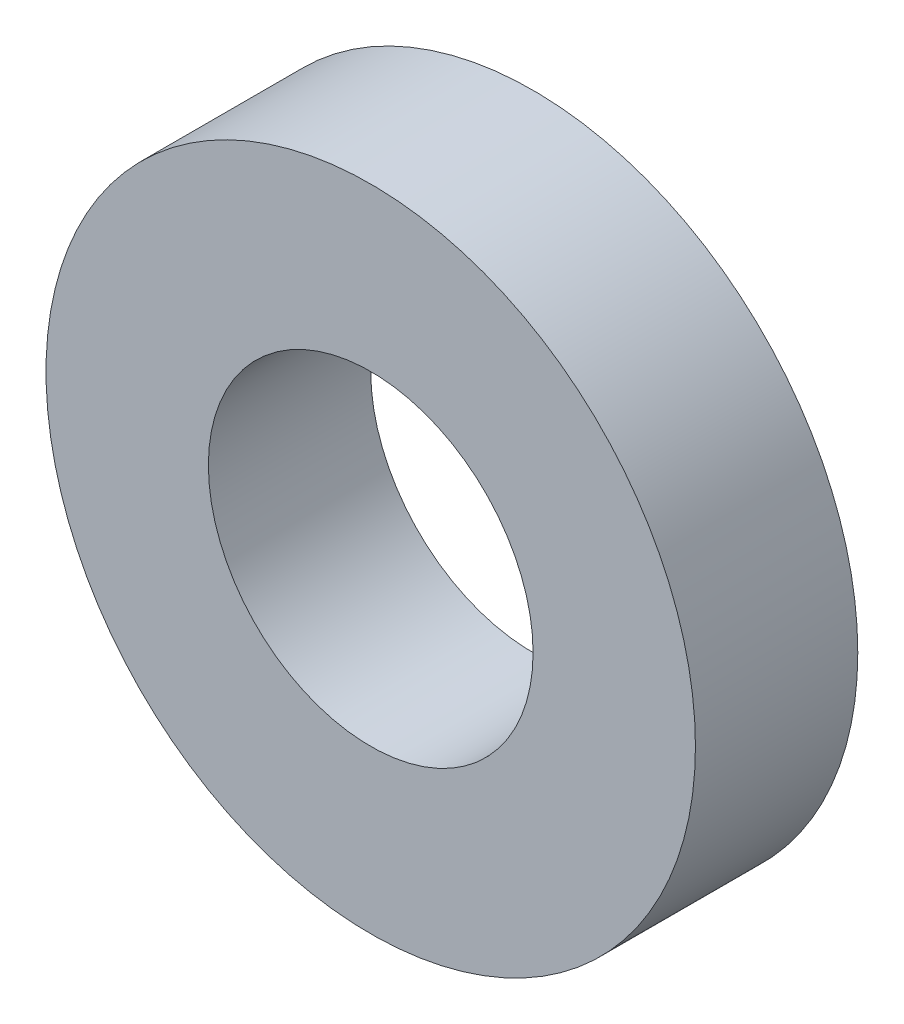
from build123d import *

# Parameters (mm, degrees)
SKETCH_1_R      = 2
SKETCH_1_R_2    = 1
EXTRUDE_1_DEPTH = 1


with BuildPart() as part:
    # 草图1 → 凸台-拉伸1 (new body)
    with BuildSketch(Plane.XY):
        Circle(SKETCH_1_R)
        Circle(SKETCH_1_R_2, mode=Mode.SUBTRACT)
    extrude(amount=EXTRUDE_1_DEPTH)


solid = part.part
